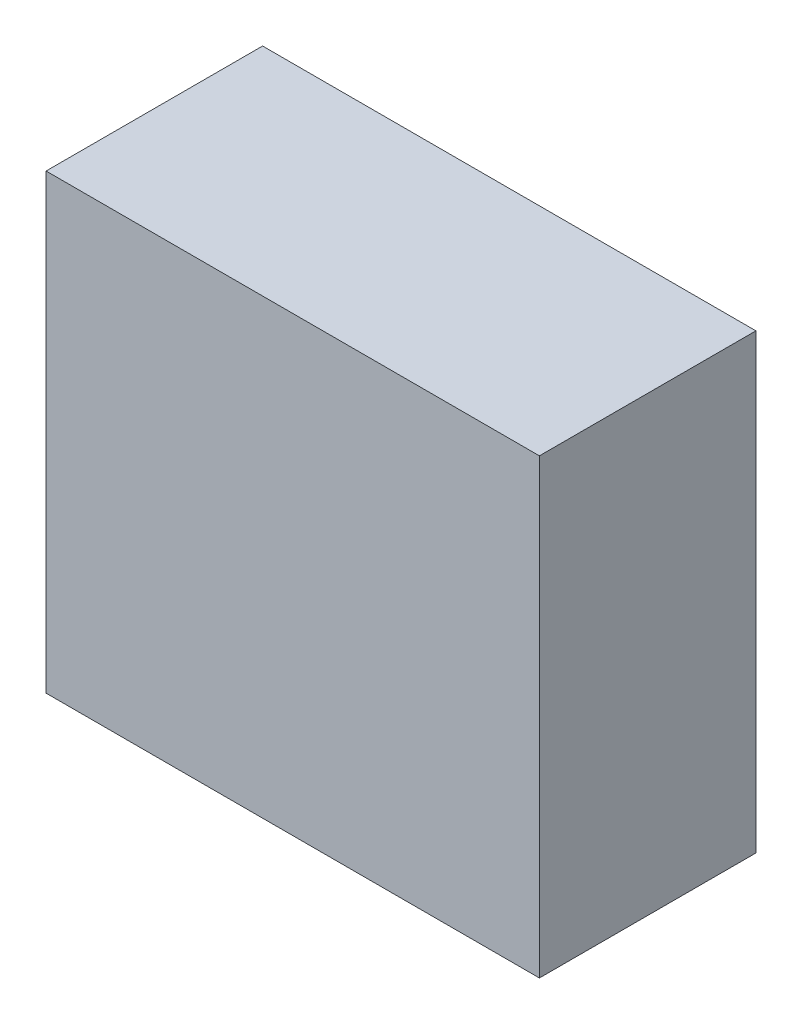
from build123d import *

# Parameters (mm, degrees)
ESBO_O1_W                = 36
ESBO_O1_H                = 33
RESSALTO_EXTRUS_O1_DEPTH = 15.8


with BuildPart() as part:
    # Esboço1 → Ressalto-extrusão1 (new body)
    with BuildSketch(Plane.XY):
        Rectangle(ESBO_O1_W, ESBO_O1_H)
    extrude(amount=RESSALTO_EXTRUS_O1_DEPTH)


solid = part.part
